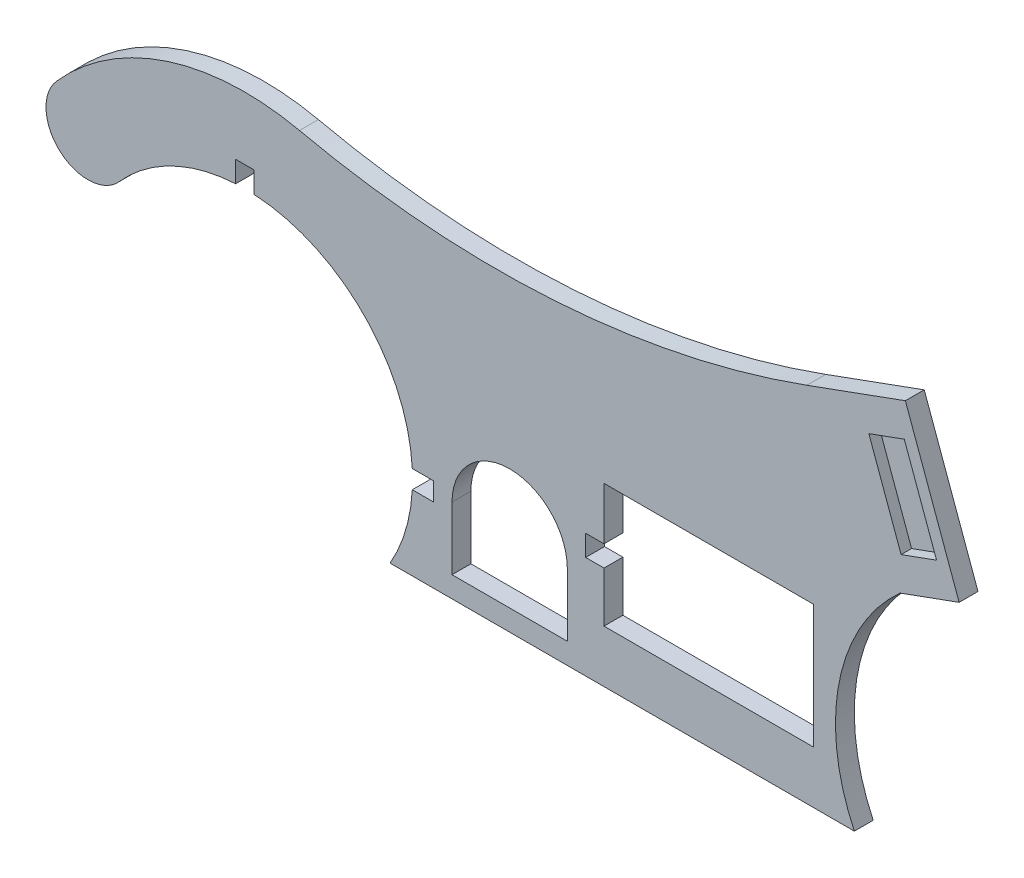
from build123d import *

# Parameters (mm, degrees)
BOSS_EXTRUDE1_DEPTH = 18
SKETCH2_W           = 200
SKETCH2_H           = 118
CUT_EXTRUDE1_DEPTH  = 19
CUT_EXTRUDE2_DEPTH  = 10
SKETCH4_W           = 17.5
SKETCH4_H           = 40
SKETCH4_W_2         = 40
SKETCH4_H_2         = 17.5
SKETCH4_H_3         = 20
CUT_EXTRUDE3_DEPTH  = 19


with BuildPart() as part:
    # Sketch1 → Boss-Extrude1 (new body)
    with BuildSketch(Plane.XY):
        with BuildLine():
            Line((0, 0), (51.303021499, -140.953893118))
            Line((51.303021499, -140.953893118), (-5.078535748, -161.475101717))
            ThreePointArc((-5.078535748, -161.475101717), (-63.089907624, -263.513472234), (-48.666413819, -380))
            Line((-48.666413819, -380), (-491.60308739, -380))
            ThreePointArc((-491.60308739, -380), (-536.64849181, -170.176041514), (-749.936822659, -193.909350133))
            ThreePointArc((-749.936822659, -193.909350133), (-806.401902791, -197.329105332), (-809.82165799, -140.864025199))
            ThreePointArc((-809.82165799, -140.864025199), (-704.170284695, -71.694204299), (-578.030994047, -65.731305902))
            ThreePointArc((-578.030994047, -65.731305902), (-333.746195792, -84.570747443), (-93.969262079, -34.202014333))
            Line((-93.969262079, -34.202014333), (0, 0))
        make_face()
    extrude(amount=BOSS_EXTRUDE1_DEPTH)

    # Sketch2 → Cut-Extrude1 (cut, through all)
    with BuildSketch(Plane.XY.offset(18)):
        with Locations((-187.508312236, -271)):
            Rectangle(SKETCH2_W, SKETCH2_H)
        with BuildLine():
            Line((-322.508312236, -360), (-432.508312236, -360))
            Line((-432.508312236, -360), (-432.508312236, -300))
            ThreePointArc((-432.508312236, -300), (-377.508312236, -245), (-322.508312236, -300))
            Line((-322.508312236, -300), (-322.508312236, -360))
        make_face()
    extrude(amount=-CUT_EXTRUDE1_DEPTH, mode=Mode.SUBTRACT)

    # Sketch3 → Cut-Extrude2 (cut)
    with BuildSketch(Plane.XY.offset(18)):
        Polygon((-1.01570715, -32.295020343), (29.76610575, -116.867356214), (-4.062828599, -129.180081374), (-34.844641498, -44.607745503), align=None)
    extrude(amount=-CUT_EXTRUDE2_DEPTH, mode=Mode.SUBTRACT)

    # Sketch4 → Cut-Extrude3 (cut, through all)
    with BuildSketch(Plane.XY.offset(18)):
        with Locations((-630.167151995, -140)):
            Rectangle(SKETCH4_W, SKETCH4_H)
        with Locations((-470.167151995, -300)):
            Rectangle(SKETCH4_W_2, SKETCH4_H_2)
        with Locations((-296.258312236, -272)):
            Rectangle(SKETCH4_W, SKETCH4_H_3)
    extrude(amount=-CUT_EXTRUDE3_DEPTH, mode=Mode.SUBTRACT)


solid = part.part
